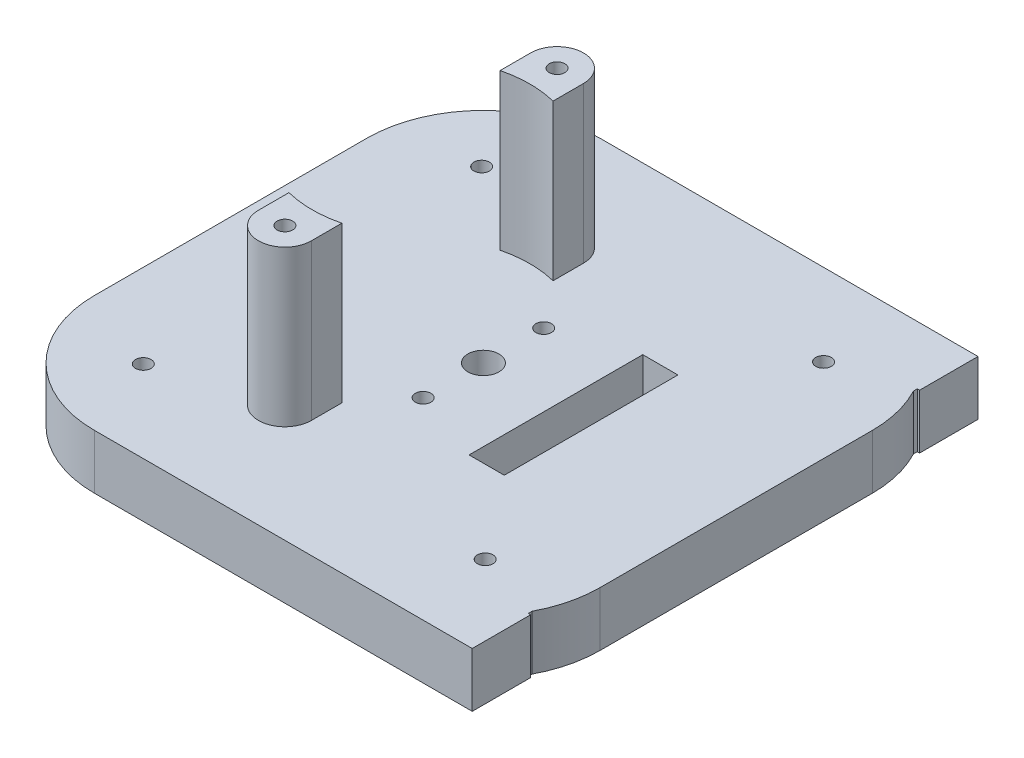
from build123d import *

# Parameters (mm, degrees)
SKETCH1_R           = 25.5
SKETCH1_R_2         = 1
SKETCH1_R_3         = 2
BOSS_EXTRUDE4_DEPTH = 7
SKETCH3_R           = 1
BOSS_EXTRUDE6_DEPTH = 20
SKETCH4_R           = 1
SKETCH4_W           = 4.52162884
SKETCH4_H           = 22.32
CUT_EXTRUDE2_DEPTH  = 10


with BuildPart() as part:
    # Sketch1 → Boss-Extrude4 (new body)
    with BuildSketch(Plane(origin=(0, 0, 0), x_dir=(1, 0, 0), z_dir=(0, 1, 0))):
        with BuildLine():
            Line((-23.098597486, 12.80927662), (-23.098597486, -22.19072338))
            ThreePointArc((-23.098597486, -22.19072338), (-18.705199204, -32.797325098), (-8.098597486, -37.19072338))
            Line((-8.098597486, -37.19072338), (40.463784198, -37.19072338))
            Line((40.463784198, -37.19072338), (40.463784198, -29.69072338))
            Line((40.463784198, -29.69072338), (40.167901675, -29.69072338))
            Line((40.167901675, -29.69072338), (40.167901675, -29.19072338))
            ThreePointArc((40.167901675, -29.19072338), (40.319108843, -28.896329756), (40.463784198, -28.598671807))
            ThreePointArc((40.463784198, -28.598671807), (41.53758585, -25.474339887), (41.901402514, -22.19072338))
            Line((41.901402514, -22.19072338), (41.901402514, 12.80927662))
            ThreePointArc((41.901402514, 12.80927662), (41.53758585, 16.092893127), (40.463784198, 19.217225047))
            ThreePointArc((40.463784198, 19.217225047), (40.319108843, 19.514882996), (40.167901675, 19.80927662))
            Line((40.167901675, 19.80927662), (40.167901675, 20.30927662))
            Line((40.167901675, 20.30927662), (40.463784198, 20.30927662))
            Line((40.463784198, 20.30927662), (40.463784198, 27.80927662))
            Line((40.463784198, 27.80927662), (-8.098597486, 27.80927662))
            ThreePointArc((-8.098597486, 27.80927662), (-18.705199204, 23.415878338), (-23.098597486, 12.80927662))
        make_face()
        with Locations((9.401402514, -4.69072338)):
            Circle(SKETCH1_R, mode=Mode.SUBTRACT)
        with Locations(Location((31.144043201, 17.278011972, 0), (0, 0, 270))):
            Circle(SKETCH1_R_2, mode=Mode.SUBTRACT)
        with Locations(Location((-12.567332839, 17.051917307, 0), (0, 0, 270))):
            Circle(SKETCH1_R_2, mode=Mode.SUBTRACT)
        with Locations(Location((-12.341238173, -26.659458733, 0), (0, 0, 270))):
            Circle(SKETCH1_R_2, mode=Mode.SUBTRACT)
        with Locations(Location((31.370137866, -26.433364067, 0), (0, 0, 270))):
            Circle(SKETCH1_R_2, mode=Mode.SUBTRACT)
        with Locations((9.401402514, -4.69072338)):
            Circle(SKETCH1_R)
        with Locations(Location((9.401402514, -4.69072338, 0), (0, 0, 270))):
            Circle(SKETCH1_R_3, mode=Mode.SUBTRACT)
    extrude(amount=BOSS_EXTRUDE4_DEPTH)

    # Sketch3 → Boss-Extrude6 (add)
    with BuildSketch(Plane(origin=(0, 7, 0), x_dir=(1, 0, 0), z_dir=(0, 1, 0))):
        with BuildLine():
            Line((-2.046619841, -18.234374208), (-2.046619841, -22.153505311))
            ThreePointArc((-2.046619841, -22.153505311), (1.353380159, -25.553505311), (4.753380159, -22.153505311))
            Line((4.753380159, -22.153505311), (4.753380159, -18.234374208))
            ThreePointArc((4.753380159, -18.234374208), (1.353380159, -18.653505311), (-2.046619841, -18.234374208))
        make_face()
        with Locations(Location((1.353380159, -22.153505311, 0), (0, 0, 270))):
            Circle(SKETCH3_R, mode=Mode.SUBTRACT)
        with BuildLine():
            Line((4.732675534, 8.927357463), (4.732675534, 12.846488565))
            ThreePointArc((4.732675534, 12.846488565), (1.332675534, 16.246488565), (-2.067324466, 12.846488565))
            Line((-2.067324466, 12.846488565), (-2.067324466, 8.927357463))
            ThreePointArc((-2.067324466, 8.927357463), (1.332675534, 9.346488565), (4.732675534, 8.927357463))
        make_face()
        with Locations(Location((1.332675534, 12.846488565, 0), (0, 0, 270))):
            Circle(SKETCH3_R, mode=Mode.SUBTRACT)
    extrude(amount=BOSS_EXTRUDE6_DEPTH)

    # Sketch4 → Cut-Extrude2 (cut)
    with BuildSketch(Plane.XZ):
        with Locations(Location((9.401402514, -3.05927662, 0), (0, 0, 270))):
            Circle(SKETCH4_R)
        with Locations(Location((9.401402514, 12.44072338, 0), (0, 0, 270))):
            Circle(SKETCH4_R)
        with Locations((20.980588094, 4.69072338)):
            Rectangle(SKETCH4_W, SKETCH4_H)
    extrude(amount=-CUT_EXTRUDE2_DEPTH, mode=Mode.SUBTRACT)


solid = part.part
